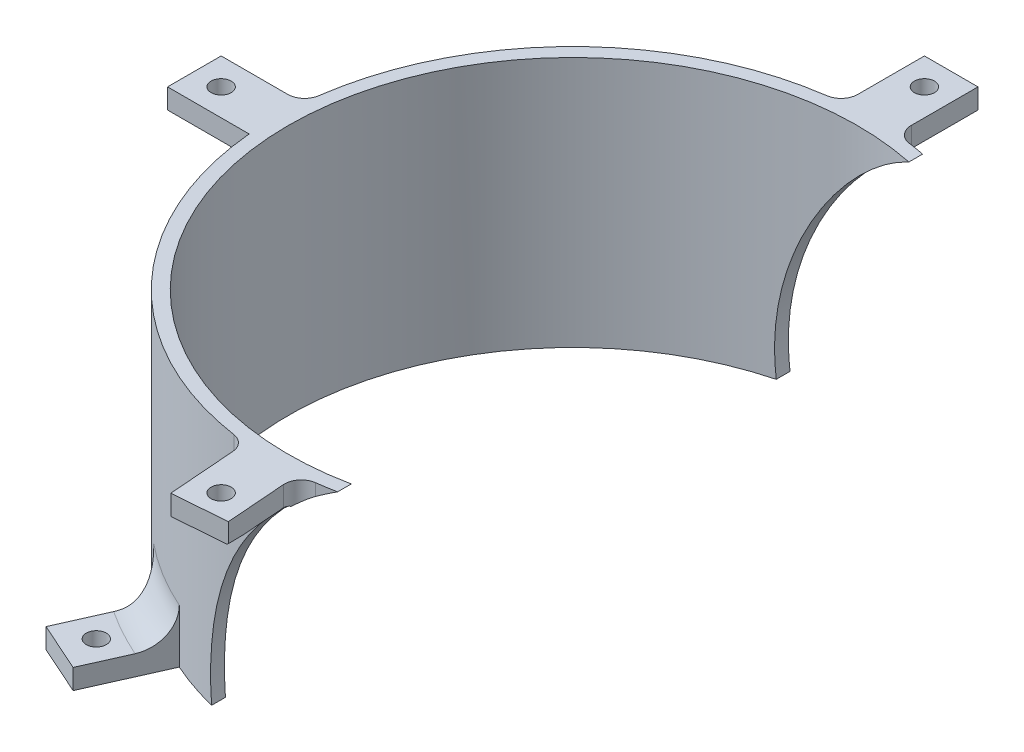
from build123d import *

# Parameters (mm, degrees)
SKETCH1_R               = 89
SKETCH1_R_2             = 85
BOSS_EXTRUDE1_DEPTH     = 75
SKETCH2_R               = 3
BOSS_EXTRUDE2_DEPTH     = 6
FILLET1_R               = 5
BOSS_EXTRUDE3_DEPTH     = 6
FILLET2_R               = 10
SKETCH4_R               = 3
CUT_EXTRUDE1_DEPTH      = 7.0000001
CUT_EXTRUDE2_DEPTH      = 113.589176878
CUT_EXTRUDE2_DEPTH_BACK = 114.0000001


with BuildPart() as part:
    # Sketch1 → Boss-Extrude1 (new body)
    with BuildSketch(Plane(origin=(0, 0, 0), x_dir=(1, 0, 0), z_dir=(0, 1, 0))):
        Circle(SKETCH1_R)
        Circle(SKETCH1_R_2, mode=Mode.SUBTRACT)
    extrude(amount=BOSS_EXTRUDE1_DEPTH)

    # Sketch2 → Boss-Extrude2 (add)
    with BuildSketch(Plane(origin=(0, 75, 0), x_dir=(1, 0, 0), z_dir=(0, 1, 0))):
        with BuildLine():
            Line((8, 86.333380616), (8, 88.639720216))
            ThreePointArc((8, 88.639720216), (0, 89), (-8, 88.639720216))
            Line((-8, 88.639720216), (-8, 86.333380616))
            Line((-8, 86.333380616), (8, 86.333380616))
        make_face()
        with BuildLine():
            ThreePointArc((-8, 88.639720216), (0, 89), (8, 88.639720216))
            Line((8, 88.639720216), (8, 113))
            Line((8, 113), (-8, 113))
            Line((-8, 113), (-8, 88.639720216))
        make_face()
        with Locations((0, 105)):
            Circle(SKETCH2_R, mode=Mode.SUBTRACT)
        with BuildLine():
            ThreePointArc((-88.639720216, -8), (-89, 0), (-88.639720216, 8))
            Line((-88.639720216, 8), (-113, 8))
            Line((-113, 8), (-113, -8))
            Line((-113, -8), (-88.639720216, -8))
        make_face()
        with Locations((-105, 0)):
            Circle(SKETCH2_R, mode=Mode.SUBTRACT)
        with BuildLine():
            Line((8.510079583, -111.370129159), (6.780952381, -88.741302023))
            ThreePointArc((6.780952381, -88.741302023), (-1.2561594, -88.991134747), (-9.283017396, -88.514550149))
            Line((-9.283017396, -88.514550149), (-7.443412916, -112.589176778))
            Line((-7.443412916, -112.589176778), (8.510079583, -111.370129159))
        make_face()
        with Locations((0, -105)):
            Circle(SKETCH2_R, mode=Mode.SUBTRACT)
    extrude(amount=-BOSS_EXTRUDE2_DEPTH)

    # Fillet1
    fillet1_edges = [part.edges().sort_by_distance(p)[0] for p in [
        (8, 72, -88.639720216),
        (-8, 72, -88.639720216),
        (0, 69, -89),
        (-88.639720216, 72, -8),
        (-89, 69, 0),
        (-9.283017396, 72, 88.514550149),
        (6.780952381, 72, 88.741302023),
        (-1.2561594, 69, 88.991134747),
    ]]
    fillet(fillet1_edges, radius=FILLET1_R)

    # Sketch3 → Boss-Extrude3 (add)
    with BuildSketch(Plane.XZ):
        Polygon((-113, 8), (-88.639720216, 8), (-86.576800688, 8), (-86.576800688, -8), (-88.639720216, -8), (-113, -8), align=None)
        Polygon((-45.961240668, -103.230636714), (-35.105734736, -78.848771193), (-49.461433174, -71.75470443), (-60.57796799, -96.722850424), align=None)
        Polygon((-35.528688012, 79.798739803), (-45.961240668, 103.230636714), (-60.57796799, 96.722850424), (-48.938573912, 70.580343301), align=None)
    extrude(amount=-BOSS_EXTRUDE3_DEPTH)

    # Fillet2
    fillet2_edges = [part.edges().sort_by_distance(p)[0] for p in [
        (-43.390130523, 6, 77.706477035),
        (-43.390130523, 6, -77.706477035),
        (-89, 6, 0),
        (-88.639720216, 3, 8),
        (-88.639720216, 3, -8),
        (-50.226514616, 3, -73.473105484),
        (-50.226514616, 3, 73.473105484),
    ]]
    fillet(fillet2_edges, radius=FILLET2_R)

    # Sketch4 → Cut-Extrude1 (cut, through all)
    with BuildSketch(Plane(origin=(0, 6, 0), x_dir=(1, 0, 0), z_dir=(0, 1, 0))):
        with Locations((-105, 0)):
            Circle(SKETCH4_R)
        with Locations((-49.891572933, -92.38956083)):
            Circle(SKETCH4_R)
        with Locations((-49.891572933, 92.38956083)):
            Circle(SKETCH4_R)
    extrude(amount=-CUT_EXTRUDE1_DEPTH, mode=Mode.SUBTRACT)

    # Sketch5 → Cut-Extrude2 (cut, two sides)
    with BuildSketch(Plane.XY) as cut_extrude2_sk:
        with BuildLine():
            Line((89, 77.46972151), (165.957699514, -10.535724009))
            Line((165.957699514, -10.535724009), (27.435871155, -65.876767842))
            Line((27.435871155, -65.876767842), (-25.198261147, -65.876767842))
            Line((-25.198261147, -65.876767842), (-21.488596465, 0))
            ThreePointArc((-21.488596465, 0), (11.032289957, 71.143366025), (89, 77.46972151))
        make_face()
    extrude(amount=CUT_EXTRUDE2_DEPTH, mode=Mode.SUBTRACT)
    extrude(cut_extrude2_sk.sketch, amount=-CUT_EXTRUDE2_DEPTH_BACK, mode=Mode.SUBTRACT)


solid = part.part
